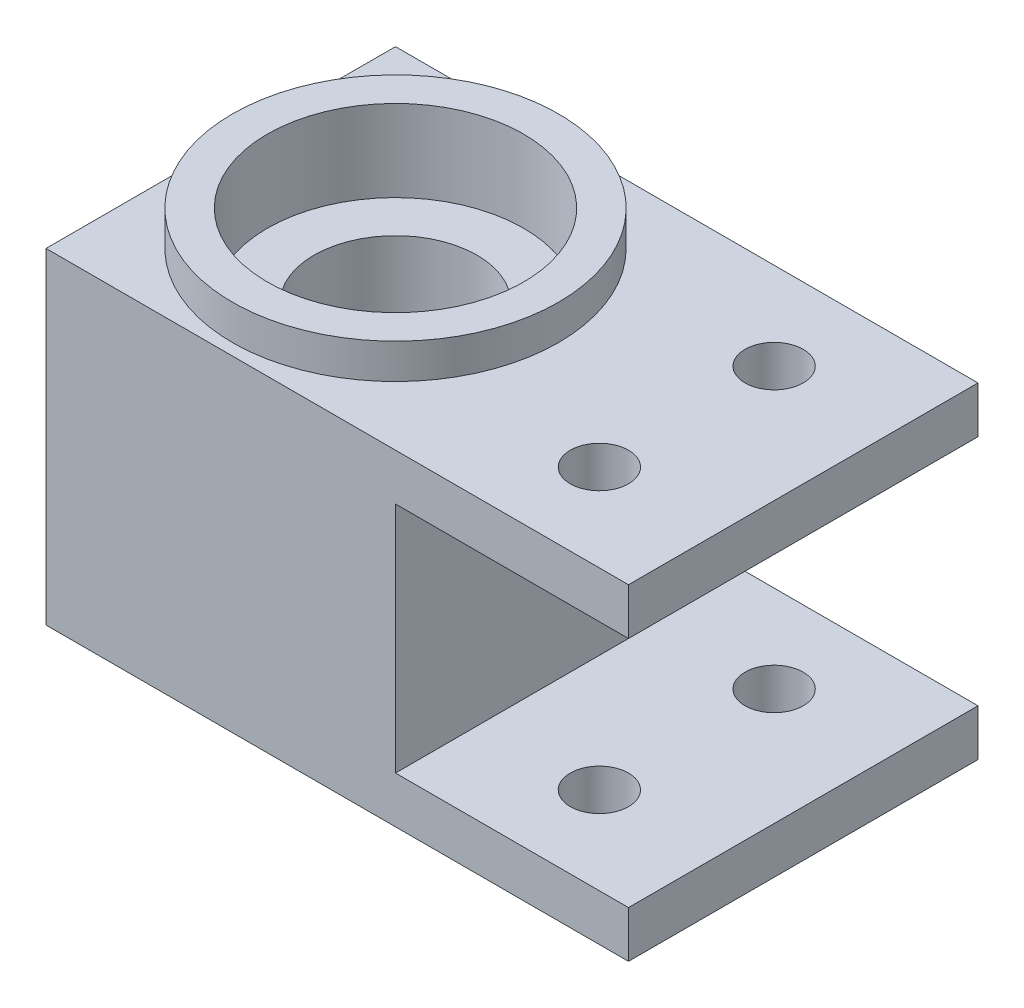
from build123d import *

# Parameters (mm, degrees)
BOSS_EXTRUDE1_DEPTH = 30
SKETCH2_R           = 7
CUT_EXTRUDE1_DEPTH  = 29
SKETCH3_R           = 11
CUT_EXTRUDE2_DEPTH  = 4
SKETCH4_R           = 11
CUT_EXTRUDE3_DEPTH  = 7
SKETCH5_R           = 2.5
CUT_EXTRUDE4_DEPTH  = 29
SKETCH6_R           = 14
SKETCH6_R_2         = 11
BOSS_EXTRUDE2_DEPTH = 3


with BuildPart() as part:
    # Sketch1 → Boss-Extrude1 (new body)
    with BuildSketch(Plane.XY):
        Polygon((10, 10), (10, 14), (-40, 14), (-40, -14), (10, -14), (10, -10), (-10, -10), (-10, 10), align=None)
    extrude(amount=BOSS_EXTRUDE1_DEPTH)

    # Sketch2 → Cut-Extrude1 (cut, through all)
    with BuildSketch(Plane(origin=(0, 14, 0), x_dir=(1, 0, 0), z_dir=(0, 1, 0))):
        with Locations((-25, -15)):
            Circle(SKETCH2_R)
    extrude(amount=-CUT_EXTRUDE1_DEPTH, mode=Mode.SUBTRACT)

    # Sketch3 → Cut-Extrude2 (cut)
    with BuildSketch(Plane(origin=(0, 14, 0), x_dir=(1, 0, 0), z_dir=(0, 1, 0))):
        with Locations((-25, -15)):
            Circle(SKETCH3_R)
    extrude(amount=-CUT_EXTRUDE2_DEPTH, mode=Mode.SUBTRACT)

    # Sketch4 → Cut-Extrude3 (cut)
    with BuildSketch(Plane.XZ.offset(14)):
        with Locations((-25, 15)):
            Circle(SKETCH4_R)
    extrude(amount=-CUT_EXTRUDE3_DEPTH, mode=Mode.SUBTRACT)

    # Sketch5 → Cut-Extrude4 (cut, through all)
    with BuildSketch(Plane(origin=(0, 14, 0), x_dir=(1, 0, 0), z_dir=(0, 1, 0))):
        with Locations((0, -22.5)):
            Circle(SKETCH5_R)
        with Locations((0, -7.5)):
            Circle(SKETCH5_R)
    extrude(amount=-CUT_EXTRUDE4_DEPTH, mode=Mode.SUBTRACT)

    # Sketch6 → Boss-Extrude2 (add)
    with BuildSketch(Plane(origin=(0, 14, 0), x_dir=(1, 0, 0), z_dir=(0, 1, 0))):
        with Locations((-25, -15)):
            Circle(SKETCH6_R)
        with Locations((-25, -15)):
            Circle(SKETCH6_R_2, mode=Mode.SUBTRACT)
    extrude(amount=BOSS_EXTRUDE2_DEPTH)


solid = part.part
